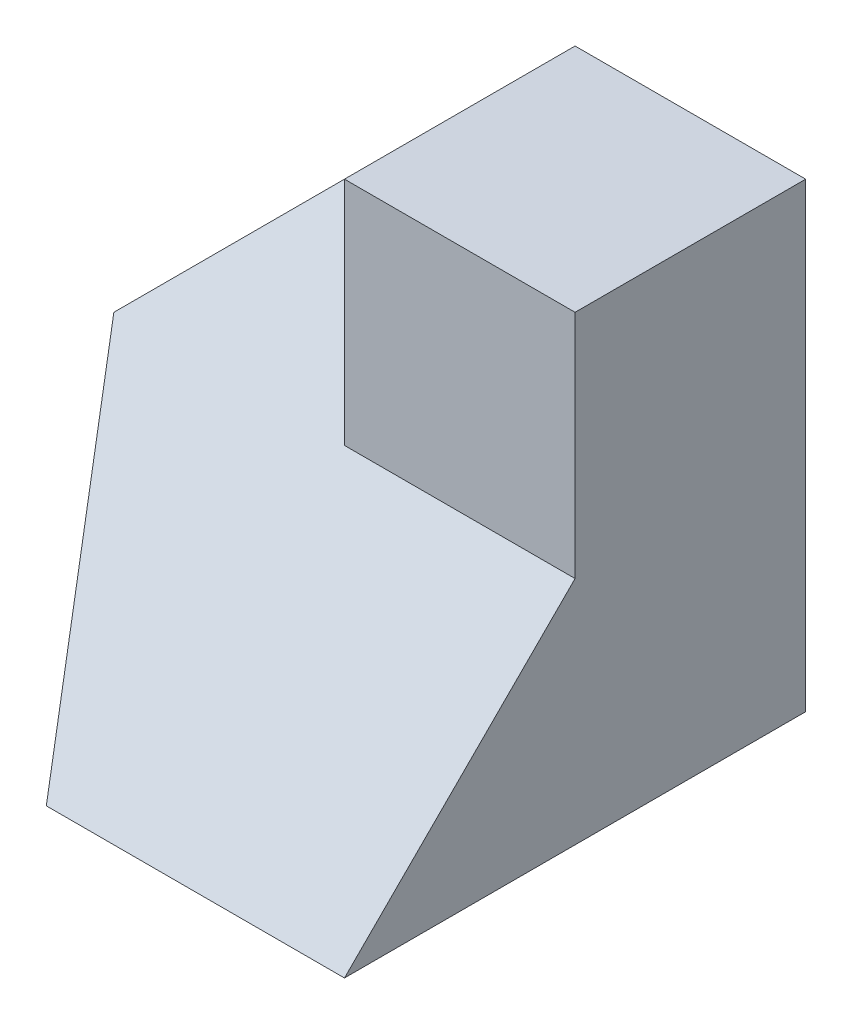
from build123d import *

# Parameters (mm, degrees)
SKETCH1_W           = 40
SKETCH1_H           = 40
BOSS_EXTRUDE1_DEPTH = 40
CUT_EXTRUDE1_DEPTH  = 40
CUT_EXTRUDE2_DEPTH  = 40
CUT_EXTRUDE3_DEPTH  = 40
SKETCH5_W           = 20
SKETCH5_H           = 40
BOSS_EXTRUDE2_DEPTH = 20


with BuildPart() as part:
    # Sketch1 → Boss-Extrude1 (new body)
    with BuildSketch(Plane.XY):
        with Locations((20, 20)):
            Rectangle(SKETCH1_W, SKETCH1_H)
    extrude(amount=BOSS_EXTRUDE1_DEPTH)

    # Sketch2 → Cut-Extrude1 (cut)
    with BuildSketch(Plane.XY.offset(40)):
        Polygon((0, 20), (0, 40), (20, 40), align=None)
    extrude(amount=-CUT_EXTRUDE1_DEPTH, mode=Mode.SUBTRACT)

    # Sketch3 → Cut-Extrude2 (cut)
    with BuildSketch(Plane.ZY):
        Polygon((40, 0), (20, 20), (0, 40), (40, 40), align=None)
    extrude(amount=-CUT_EXTRUDE2_DEPTH, mode=Mode.SUBTRACT)

    # Sketch4 → Cut-Extrude3 (cut)
    with BuildSketch(Plane(origin=(0, 20, 20), x_dir=(1, 0, 0), z_dir=(0, 0.707106781, 0.707106781))):
        Polygon((0, 0), (20, -40), (0, -40), align=None)
    extrude(amount=-CUT_EXTRUDE3_DEPTH, mode=Mode.SUBTRACT)

    # Sketch5 → Boss-Extrude2 (add)
    with BuildSketch(Plane(origin=(40, 0, 0), x_dir=(0, 0, -1), z_dir=(1, 0, 0))):
        with Locations((-10, 20)):
            Rectangle(SKETCH5_W, SKETCH5_H)
    extrude(amount=-BOSS_EXTRUDE2_DEPTH)


solid = part.part
